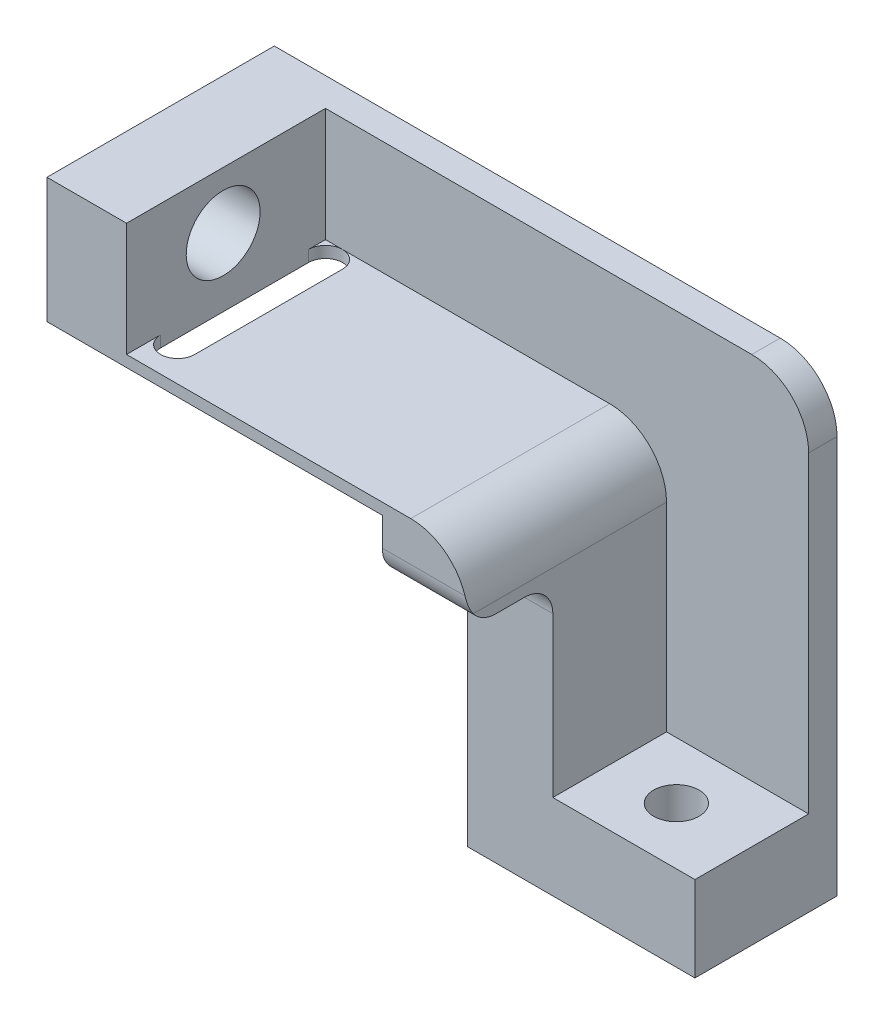
from build123d import *

# Parameters (mm, degrees)
BOSS_EXTRUDE1_DEPTH     = 40
SKETCH2_R               = 4
CUT_EXTRUDE1_DEPTH      = 30
CUT_EXTRUDE2_DEPTH      = 100
CUT_EXTRUDE2_DEPTH_BACK = 100
SKETCH3_R               = 6.5
SKETCH5_W               = 35
SKETCH5_H               = 20
CUT_EXTRUDE3_DEPTH      = 60
SKETCH6_W               = 5
SKETCH6_H               = 65
BOSS_EXTRUDE2_DEPTH     = 25
CUT_EXTRUDE4_DEPTH      = 10
FILLET1_R               = 10
SKETCH8_W               = 40
SKETCH8_H               = 48
CUT_EXTRUDE5_DEPTH      = 15
FILLET2_R               = 5


with BuildPart() as part:
    # Sketch1 → Boss-Extrude1 (new body)
    with BuildSketch(Plane.XY):
        Polygon((40, -23.325428286), (0, -23.325428286), (0, 34.674571714), (-59, 34.674571714), (-59, 56.674571714), (15, 56.674571714), (15, -8.325428286), (40, -8.325428286), align=None)
    extrude(amount=BOSS_EXTRUDE1_DEPTH)

    # Sketch2 → Cut-Extrude1 (cut)
    with BuildSketch(Plane(origin=(0, -8.325428286, 0), x_dir=(1, 0, 0), z_dir=(0, 1, 0))):
        with Locations((26.730150284, -15)):
            Circle(SKETCH2_R)
    extrude(amount=-CUT_EXTRUDE1_DEPTH, mode=Mode.SUBTRACT)

    # Sketch3 → Cut-Extrude2 (cut, two sides: drawn at the far end of the back side and taken through both)
    with BuildSketch(Plane(origin=(-59, 0, 0), x_dir=(0, 0, -1), z_dir=(1, 0, 0)).offset(-CUT_EXTRUDE2_DEPTH_BACK)):
        with Locations((-23, 46.674571714)):
            Circle(SKETCH3_R)
    extrude(amount=CUT_EXTRUDE2_DEPTH + CUT_EXTRUDE2_DEPTH_BACK, mode=Mode.SUBTRACT)

    # Sketch5 → Cut-Extrude3 (cut)
    with BuildSketch(Plane(origin=(15, 0, 0), x_dir=(0, 0, -1), z_dir=(1, 0, 0))):
        with Locations((-22.5, 46.674571714)):
            Rectangle(SKETCH5_W, SKETCH5_H)
    extrude(amount=-CUT_EXTRUDE3_DEPTH, mode=Mode.SUBTRACT)

    # Sketch6 → Boss-Extrude2 (add)
    with BuildSketch(Plane(origin=(15, 0, 0), x_dir=(0, 0, -1), z_dir=(1, 0, 0))):
        with Locations((-2.5, 24.174571714)):
            Rectangle(SKETCH6_W, SKETCH6_H)
    extrude(amount=BOSS_EXTRUDE2_DEPTH)

    # Sketch7 → Cut-Extrude4 (cut)
    with BuildSketch(Plane(origin=(0, 36.674571714, 0), x_dir=(1, 0, 0), z_dir=(0, 1, 0))):
        with BuildLine():
            Line((-39, -8), (-39, -34))
            ThreePointArc((-39, -34), (-42, -37), (-45, -34))
            Line((-45, -34), (-45, -8))
            ThreePointArc((-45, -8), (-42, -5), (-39, -8))
        make_face()
    extrude(amount=-CUT_EXTRUDE4_DEPTH, mode=Mode.SUBTRACT)

    # Fillet1
    fillet1_edges = [part.edges().sort_by_distance(p)[0] for p in [
        (15, 36.674571714, 22.5),
        (40, 56.674571714, 2.5),
    ]]
    fillet(fillet1_edges, radius=FILLET1_R)

    # Sketch8 → Cut-Extrude5 (cut)
    with BuildSketch(Plane.XY.offset(40)):
        with Locations((20, 0.674571714)):
            Rectangle(SKETCH8_W, SKETCH8_H)
    extrude(amount=-CUT_EXTRUDE5_DEPTH, mode=Mode.SUBTRACT)

    # Fillet2
    fillet2_edges = [part.edges().sort_by_distance(p)[0] for p in [
        (7.5, 24.674571714, 40),
        (7.5, 24.674571714, 25),
    ]]
    fillet(fillet2_edges, radius=FILLET2_R)


solid = part.part
